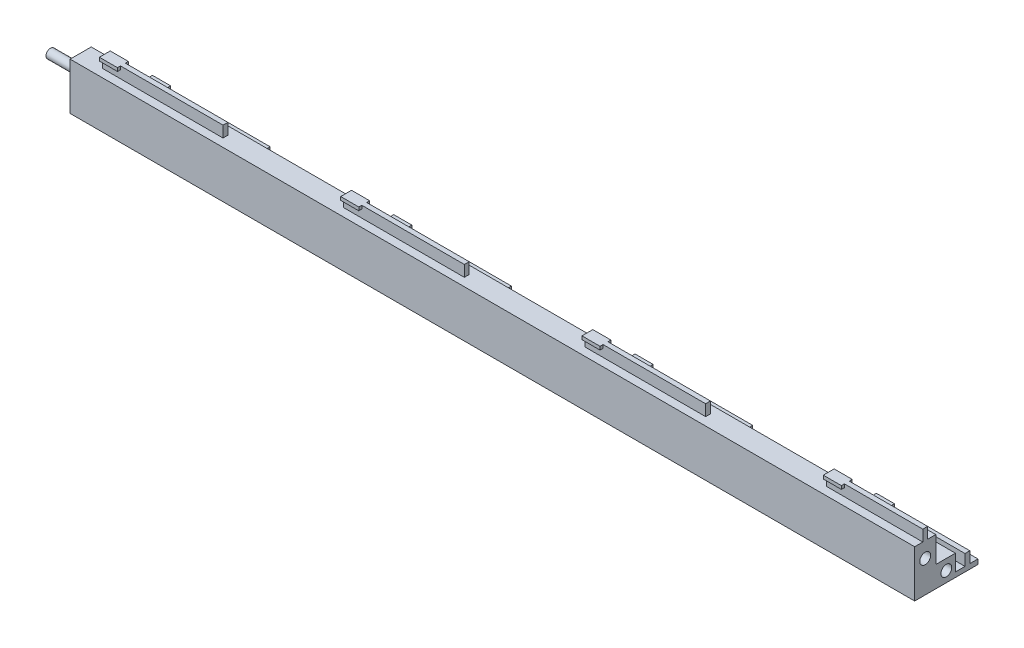
from build123d import *

# Parameters (mm, degrees)
BOSS_EXTRUDE1_DEPTH = 140
SKETCH1_5_R         = 0.75
BOSS_EXTRUDE2_DEPTH = 5
SKETCH2_R           = 0.9
CUT_EXTRUDE1_DEPTH  = 6
SKETCH3_W           = 0.25
SKETCH3_H           = 2.7
CUT_EXTRUDE2_DEPTH  = 171.537268104
SKETCH4_W           = 13
SKETCH4_H           = 1.35
SKETCH4_W_2         = 37
SKETCH4_W_3         = 4
SKETCH4_W_4         = 30
CUT_EXTRUDE4_DEPTH  = 86.663575277
SKETCH6_W           = 13
SKETCH6_H           = 1.35
SKETCH6_W_2         = 37
SKETCH6_W_3         = 24
CUT_EXTRUDE5_DEPTH  = 86.765556194
SKETCH7_W           = 20
SKETCH7_H           = 1.8
CUT_EXTRUDE6_DEPTH  = 86.663575277
SKETCH8_W           = 20
SKETCH8_H           = 1.8
CUT_EXTRUDE7_DEPTH  = 86.765556194


with BuildPart() as part:
    # Sketch1 → Boss-Extrude1 (new body)
    with BuildSketch(Plane(origin=(-58.146340827, 0, 0), x_dir=(0, 0, -1), z_dir=(1, 0, 0))):
        Polygon((-20.52887033, 84.640306989), (-21.87887033, 84.640306989), (-21.87887033, 85.940306989), (-21.37887033, 85.940306989), (-21.37887033, 86.490306989), (-23.17887033, 86.490306989), (-23.17887033, 85.940306989), (-22.67887033, 85.940306989), (-22.67887033, 84.640306989), (-24.02887033, 84.640306989), (-24.02887033, 76.840306989), (-13.52887033, 76.840306989), (-13.52887033, 77.640306989), (-14.87887033, 77.640306989), (-14.87887033, 78.940306989), (-14.37887033, 78.940306989), (-14.37887033, 79.490306989), (-16.17887033, 79.490306989), (-16.17887033, 78.940306989), (-15.67887033, 78.940306989), (-15.67887033, 77.640306989), (-17.02887033, 77.640306989), (-17.02887033, 80.340306989), (-20.52887033, 80.340306989), align=None)
    extrude(amount=BOSS_EXTRUDE1_DEPTH)

    # Sketch1_5 → Boss-Extrude2 (add)
    with BuildSketch(Plane(origin=(-58.146340827, 0, 0), x_dir=(0, 0, -1), z_dir=(1, 0, 0))):
        with Locations((-22.27887033, 82.090306989)):
            Circle(SKETCH1_5_R)
        with Locations((-18.77887033, 78.590306989)):
            Circle(SKETCH1_5_R)
    extrude(amount=-BOSS_EXTRUDE2_DEPTH)

    # Sketch2 → Cut-Extrude1 (cut)
    with BuildSketch(Plane(origin=(81.853659173, 0, 0), x_dir=(0, 0, -1), z_dir=(1, 0, 0))):
        with Locations((-22.27887033, 82.090306989)):
            Circle(SKETCH2_R)
        with Locations((-18.77887033, 78.590306989)):
            Circle(SKETCH2_R)
    extrude(amount=-CUT_EXTRUDE1_DEPTH, mode=Mode.SUBTRACT)

    # Sketch3 → Cut-Extrude2 (cut, through all)
    with BuildSketch(Plane(origin=(81.853659173, 0, 0), x_dir=(0, 0, -1), z_dir=(1, 0, 0))):
        with Locations((-17.15387033, 78.990306989)):
            Rectangle(SKETCH3_W, SKETCH3_H)
    extrude(amount=-CUT_EXTRUDE2_DEPTH, mode=Mode.SUBTRACT)

    # Sketch4 → Cut-Extrude4 (cut, through all)
    with BuildSketch(Plane(origin=(0, 84.640306989, 0), x_dir=(1, 0, 0), z_dir=(0, 1, 0))):
        with Locations((75.353659173, -21.20387033)):
            Rectangle(SKETCH4_W, SKETCH4_H)
        with Locations((75.353659173, -23.35387033)):
            Rectangle(SKETCH4_W, SKETCH4_H)
        with Locations((47.353659173, -23.35387033)):
            Rectangle(SKETCH4_W_2, SKETCH4_H)
        with Locations((7.353659173, -23.35387033)):
            Rectangle(SKETCH4_W_2, SKETCH4_H)
        with Locations((-32.646340827, -23.35387033)):
            Rectangle(SKETCH4_W_2, SKETCH4_H)
        with Locations((-56.146340827, -23.35387033)):
            Rectangle(SKETCH4_W_3, SKETCH4_H)
        with Locations((47.353659173, -21.20387033)):
            Rectangle(SKETCH4_W_2, SKETCH4_H)
        with Locations((7.353659173, -21.20387033)):
            Rectangle(SKETCH4_W_2, SKETCH4_H)
        with Locations((-32.646340827, -21.20387033)):
            Rectangle(SKETCH4_W_2, SKETCH4_H)
        with Locations((-69.146340827, -21.20387033)):
            Rectangle(SKETCH4_W_4, SKETCH4_H)
    extrude(amount=CUT_EXTRUDE4_DEPTH, mode=Mode.SUBTRACT)

    # Sketch6 → Cut-Extrude5 (cut, through all)
    with BuildSketch(Plane(origin=(0, 77.640306989, 0), x_dir=(1, 0, 0), z_dir=(0, 1, 0))):
        with Locations((75.353659173, -14.20387033)):
            Rectangle(SKETCH6_W, SKETCH6_H)
        with Locations((47.353659173, -14.20387033)):
            Rectangle(SKETCH6_W_2, SKETCH6_H)
        with Locations((7.353659173, -14.20387033)):
            Rectangle(SKETCH6_W_2, SKETCH6_H)
        with Locations((-32.646340827, -14.20387033)):
            Rectangle(SKETCH6_W_2, SKETCH6_H)
        with Locations((-66.146340827, -14.20387033)):
            Rectangle(SKETCH6_W_3, SKETCH6_H)
        with Locations((75.353659173, -16.35387033)):
            Rectangle(SKETCH6_W, SKETCH6_H)
        with Locations((47.353659173, -16.35387033)):
            Rectangle(SKETCH6_W_2, SKETCH6_H)
        with Locations((7.353659173, -16.35387033)):
            Rectangle(SKETCH6_W_2, SKETCH6_H)
        with Locations((-32.646340827, -16.35387033)):
            Rectangle(SKETCH6_W_2, SKETCH6_H)
        with Locations((-66.146340827, -16.35387033)):
            Rectangle(SKETCH6_W_3, SKETCH6_H)
    extrude(amount=CUT_EXTRUDE5_DEPTH, mode=Mode.SUBTRACT)

    # Sketch7 → Cut-Extrude6 (cut, through all)
    with BuildSketch(Plane(origin=(0, 84.640306989, 0), x_dir=(1, 0, 0), z_dir=(0, 1, 0))):
        with Locations((55.853659173, -22.27887033)):
            Rectangle(SKETCH7_W, SKETCH7_H)
        with Locations((15.853659173, -22.27887033)):
            Rectangle(SKETCH7_W, SKETCH7_H)
        with Locations((-24.146340827, -22.27887033)):
            Rectangle(SKETCH7_W, SKETCH7_H)
        with Locations((-64.146340827, -22.27887033)):
            Rectangle(SKETCH7_W, SKETCH7_H)
    extrude(amount=CUT_EXTRUDE6_DEPTH, mode=Mode.SUBTRACT)

    # Sketch8 → Cut-Extrude7 (cut, through all)
    with BuildSketch(Plane(origin=(0, 77.640306989, 0), x_dir=(1, 0, 0), z_dir=(0, 1, 0))):
        with Locations((55.853659173, -15.27887033)):
            Rectangle(SKETCH8_W, SKETCH8_H)
        with Locations((15.853659173, -15.27887033)):
            Rectangle(SKETCH8_W, SKETCH8_H)
        with Locations((-24.146340827, -15.27887033)):
            Rectangle(SKETCH8_W, SKETCH8_H)
        with Locations((-64.146340827, -15.27887033)):
            Rectangle(SKETCH8_W, SKETCH8_H)
    extrude(amount=CUT_EXTRUDE7_DEPTH, mode=Mode.SUBTRACT)


solid = part.part
